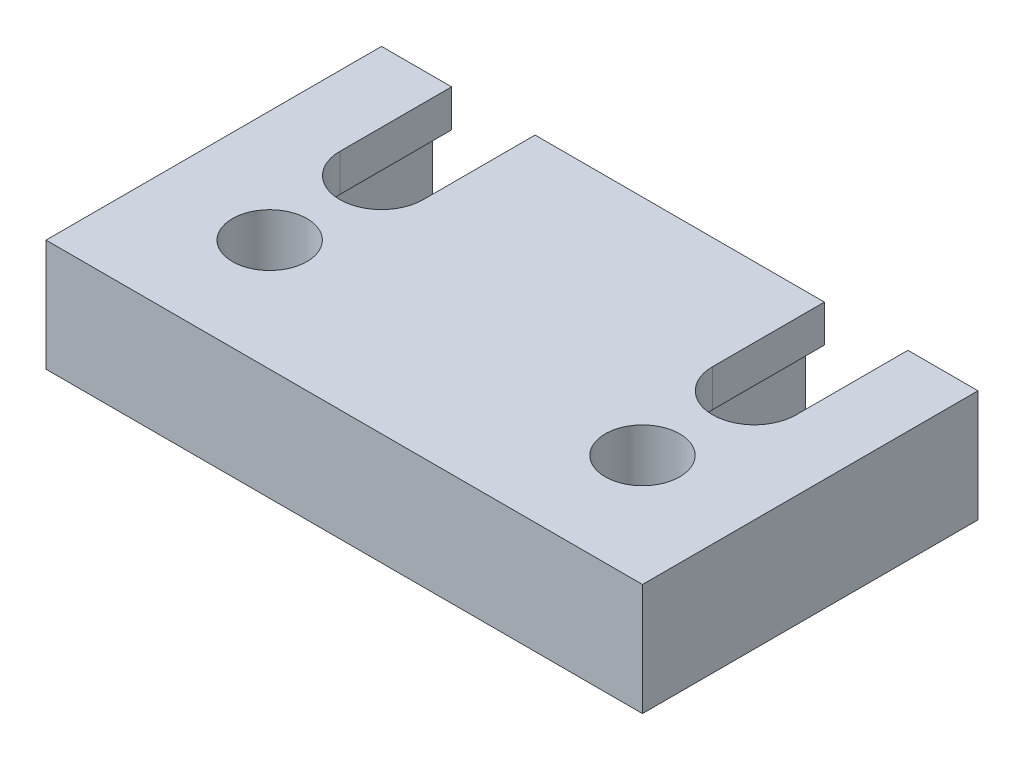
from build123d import *

# Parameters (mm, degrees)
SKETCH1_W               = 114.3
SKETCH1_H               = 76.2
BASE_EXTRUDE_DEPTH      = 19.05
F_1_2_20_TAPPED_HOLE1_D = 12.7
CUT_EXTRUDE1_DEPTH      = 12.7
CUT_EXTRUDE2_DEPTH      = 12.7
SKETCH7_W               = 6.35
SKETCH7_H               = 76.2
CUT_EXTRUDE3_DEPTH      = 1
CUT_EXTRUDE3_DEPTH_BACK = 20.05
SKETCH8_W               = 6.35
SKETCH8_H               = 76.2
CUT_EXTRUDE4_DEPTH      = 1
CUT_EXTRUDE4_DEPTH_BACK = 20.05
CUT_EXTRUDE5_DEPTH      = 1
CUT_EXTRUDE5_DEPTH_BACK = 20.05


with BuildPart() as part:
    # Sketch1 → Base-Extrude (new body)
    with BuildSketch(Plane(origin=(0, 0, 0), x_dir=(1, 0, 0), z_dir=(0, 1, 0))):
        with Locations((57.15, 38.1)):
            Rectangle(SKETCH1_W, SKETCH1_H)
        with BuildLine():
            Line((96.012, 63.5), (96.012, 38.1))
            ThreePointArc((96.012, 38.1), (88.9, 30.988), (81.788, 38.1))
            Line((81.788, 38.1), (81.788, 63.5))
            ThreePointArc((81.788, 63.5), (88.9, 70.612), (96.012, 63.5))
        make_face(mode=Mode.SUBTRACT)
        with BuildLine():
            Line((18.288, 63.5), (18.288, 38.1))
            ThreePointArc((18.288, 38.1), (25.4, 30.988), (32.512, 38.1))
            Line((32.512, 38.1), (32.512, 63.5))
            ThreePointArc((32.512, 63.5), (25.4, 70.612), (18.288, 63.5))
        make_face(mode=Mode.SUBTRACT)
    extrude(amount=BASE_EXTRUDE_DEPTH)

    # 1/2-20 Tapped Hole1 (through all)
    with Locations(Plane(origin=(0, 19.05, 0), x_dir=(-1, 0, 0), z_dir=(0, 1, 0))):
        with Locations((-25.4, -19.05), (-88.9, -19.05)):
            Hole(F_1_2_20_TAPPED_HOLE1_D / 2)

    # Sketch4 → Cut-Extrude1 (cut)
    with BuildSketch(Plane.XZ):
        with BuildLine():
            Line((15.0749, -63.5), (15.0749, -38.1))
            ThreePointArc((15.0749, -38.1), (25.4, -27.7749), (35.7251, -38.1))
            Line((35.7251, -38.1), (35.7251, -63.5))
            ThreePointArc((35.7251, -63.5), (25.4, -73.8251), (15.0749, -63.5))
        make_face()
    extrude(amount=-CUT_EXTRUDE1_DEPTH, mode=Mode.SUBTRACT)

    # Sketch5 → Cut-Extrude2 (cut)
    with BuildSketch(Plane.XZ):
        with BuildLine():
            Line((99.2251, -38.1), (99.2251, -63.5))
            ThreePointArc((99.2251, -63.5), (88.9, -73.8251), (78.5749, -63.5))
            Line((78.5749, -63.5), (78.5749, -38.1))
            ThreePointArc((78.5749, -38.1), (88.9, -27.7749), (99.2251, -38.1))
        make_face()
    extrude(amount=-CUT_EXTRUDE2_DEPTH, mode=Mode.SUBTRACT)

    # Sketch7 → Cut-Extrude3 (cut, two sides)
    with BuildSketch(Plane.XZ) as cut_extrude3_sk:
        with Locations((111.125, -38.1)):
            Rectangle(SKETCH7_W, SKETCH7_H)
    extrude(amount=CUT_EXTRUDE3_DEPTH, mode=Mode.SUBTRACT)
    extrude(cut_extrude3_sk.sketch, amount=-CUT_EXTRUDE3_DEPTH_BACK, mode=Mode.SUBTRACT)

    # Sketch8 → Cut-Extrude4 (cut, two sides)
    with BuildSketch(Plane.XZ) as cut_extrude4_sk:
        with Locations((3.175, -38.1)):
            Rectangle(SKETCH8_W, SKETCH8_H)
    extrude(amount=CUT_EXTRUDE4_DEPTH, mode=Mode.SUBTRACT)
    extrude(cut_extrude4_sk.sketch, amount=-CUT_EXTRUDE4_DEPTH_BACK, mode=Mode.SUBTRACT)

    # Sketch9 → Cut-Extrude5 (cut, two sides)
    with BuildSketch(Plane.XZ) as cut_extrude5_sk:
        Polygon((351.091008834, -57.15), (107.95, -57.15), (6.35, -57.15), (-236.791008834, -57.15), (-236.791008834, -543.432017667), (351.091008834, -543.432017667), align=None)
    extrude(amount=CUT_EXTRUDE5_DEPTH, mode=Mode.SUBTRACT)
    extrude(cut_extrude5_sk.sketch, amount=-CUT_EXTRUDE5_DEPTH_BACK, mode=Mode.SUBTRACT)


solid = part.part
